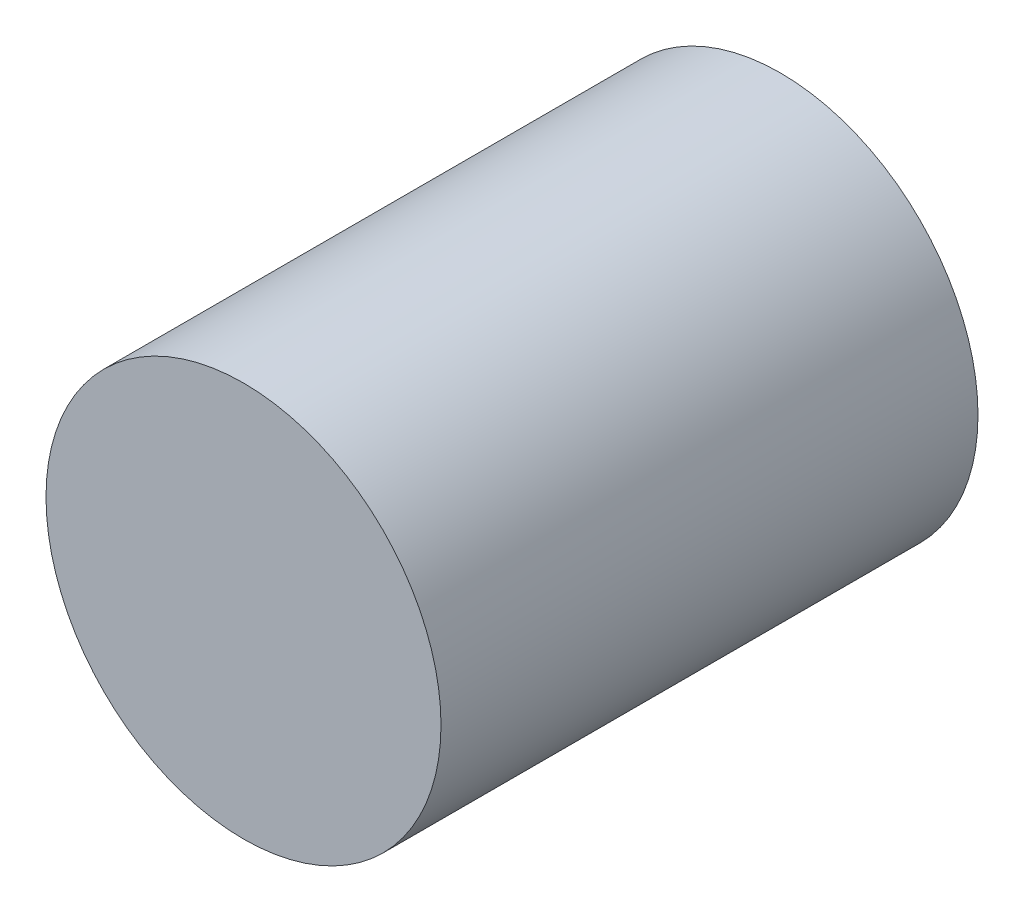
from build123d import *

# Parameters (mm, degrees)
SKETCH2_R           = 21
BOSS_EXTRUDE1_DEPTH = 57.1


with BuildPart() as part:
    # Sketch2 → Boss-Extrude1 (new body)
    with BuildSketch(Plane.XY):
        Circle(SKETCH2_R)
    extrude(amount=BOSS_EXTRUDE1_DEPTH)


solid = part.part
